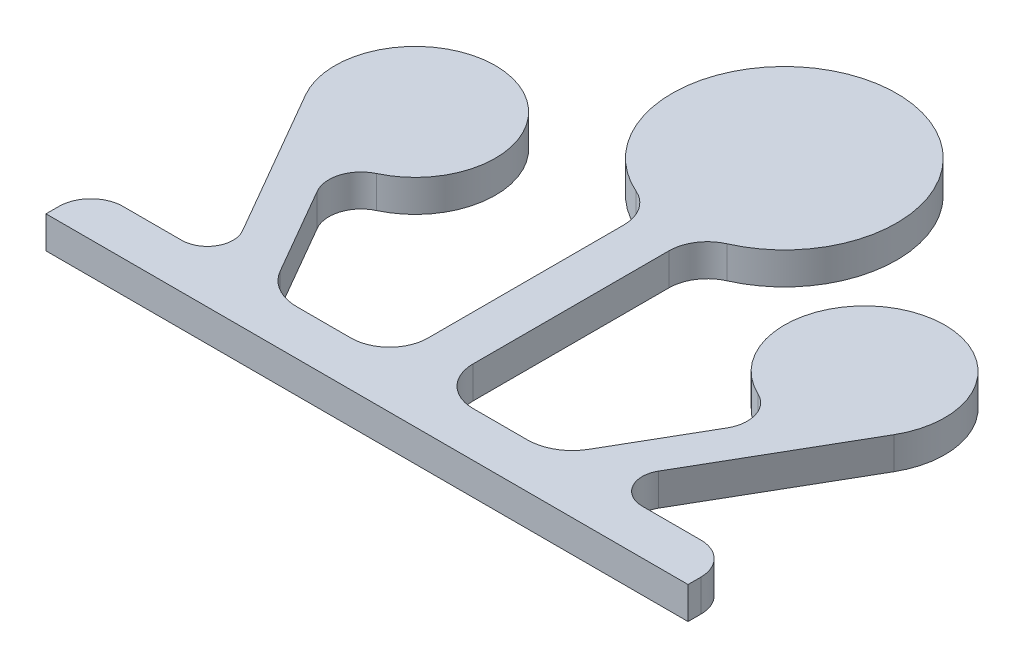
from build123d import *

# Parameters (mm, degrees)
SKETCH_201_R    = 35
EXTRUDE_1_DEPTH = 10
SKETCH_7_R      = 25
EXTRUDE_2_DEPTH = 10
SKETCH_8_R      = 25
EXTRUDE_3_DEPTH = 10
EXTRUDE_4_DEPTH = 10
EXTRUDE_8_DEPTH = 10


with BuildPart() as part:
    # Sketch 201 → Бобышка-Вытянуть1 (new body)
    with BuildSketch(Plane(origin=(0, 0, 0), x_dir=(1, 0, 0), z_dir=(0, 1, 0))):
        Circle(SKETCH_201_R)
    extrude(amount=EXTRUDE_1_DEPTH)



with BuildPart() as body_2:
    # Эскиз<7> → Бобышка-Вытянуть2 (new body)
    with BuildSketch(Plane(origin=(0, 0, 0), x_dir=(1, 0, 0), z_dir=(0, 1, 0))):
        with Locations((-70, -45)):
            Circle(SKETCH_7_R)
    extrude(amount=EXTRUDE_2_DEPTH)


with BuildPart() as body_3:
    # Эскиз<8> → Бобышка-Вытянуть3 (new body)
    with BuildSketch(Plane(origin=(0, 0, 0), x_dir=(1, 0, 0), z_dir=(0, 1, 0))):
        with Locations((70, -45)):
            Circle(SKETCH_8_R)
    extrude(amount=EXTRUDE_3_DEPTH)


with BuildPart() as body_4:
    # Эскиз<9> → Бобышка-Вытянуть4 (new body)
    with BuildSketch(Plane(origin=(0, 0, 0), x_dir=(1, 0, 0), z_dir=(0, 1, 0))):
        with BuildLine():
            Line((-90, -116), (90, -116))
            ThreePointArc((90, -116), (97.071067812, -118.928932188), (100, -126))
            Line((100, -126), (100, -130))
            Line((100, -130), (-100, -130))
            Line((-100, -130), (-100, -126))
            ThreePointArc((-100, -126), (-97.071067812, -118.928932188), (-90, -116))
        make_face()
    extrude(amount=EXTRUDE_4_DEPTH)


with BuildPart() as part_1:
    add(part.part)

    add(body_2.part)  # Бобышка-Вытянуть8 merges body 2

    add(body_3.part)  # Бобышка-Вытянуть8 merges body 3

    add(body_4.part)  # Бобышка-Вытянуть8 merges body 4
    # Эскиз<21> → Бобышка-Вытянуть8 (add)
    with BuildSketch(Plane(origin=(0, 0, 0), x_dir=(1, 0, 0), z_dir=(0, 1, 0))):
        with BuildLine():
            Line((7, -104), (7, -42.98837052))
            ThreePointArc((7, -42.98837052), (8.944833021, -36.439048645), (14.14893617, -32.012616345))
            ThreePointArc((14.14893617, -32.012616345), (0, -35), (-14.14893617, -32.012616345))
            ThreePointArc((-14.14893617, -32.012616345), (-8.944833021, -36.439048645), (-7, -42.98837052))
            Line((-7, -42.98837052), (-7, -104))
            ThreePointArc((-7, -104), (-10.514718626, -112.485281374), (-19, -116))
            Line((-19, -116), (19, -116))
            ThreePointArc((19, -116), (10.514718626, -112.485281374), (7, -104))
        make_face()
        with BuildLine():
            ThreePointArc((48.060689771, -109), (42.936334118, -114.124355653), (35.936334118, -116))
            Line((35.936334118, -116), (71.732050808, -116))
            ThreePointArc((71.732050808, -116), (64.803847577, -112), (64.803847577, -104))
            Line((64.803847577, -104), (91.650635095, -57.5))
            ThreePointArc((91.650635095, -57.5), (77.500394191, -68.848356064), (59.401771741, -67.642384101))
            ThreePointArc((59.401771741, -67.642384101), (64.701822863, -73.699180065), (63.822734475, -81.699337741))
            Line((63.822734475, -81.699337741), (48.060689771, -109))
        make_face()
        with BuildLine():
            Line((-71.732050808, -116), (-35.936334118, -116))
            ThreePointArc((-35.936334118, -116), (-42.936334118, -114.124355653), (-48.060689771, -109))
            Line((-48.060689771, -109), (-63.822734475, -81.699337741))
            ThreePointArc((-63.822734475, -81.699337741), (-64.701822863, -73.699180065), (-59.401771741, -67.642384101))
            ThreePointArc((-59.401771741, -67.642384101), (-77.500394191, -68.848356064), (-91.650635095, -57.5))
            Line((-91.650635095, -57.5), (-64.803847577, -104))
            ThreePointArc((-64.803847577, -104), (-64.803847577, -112), (-71.732050808, -116))
        make_face()
    extrude(amount=EXTRUDE_8_DEPTH)


solid = part_1.part
